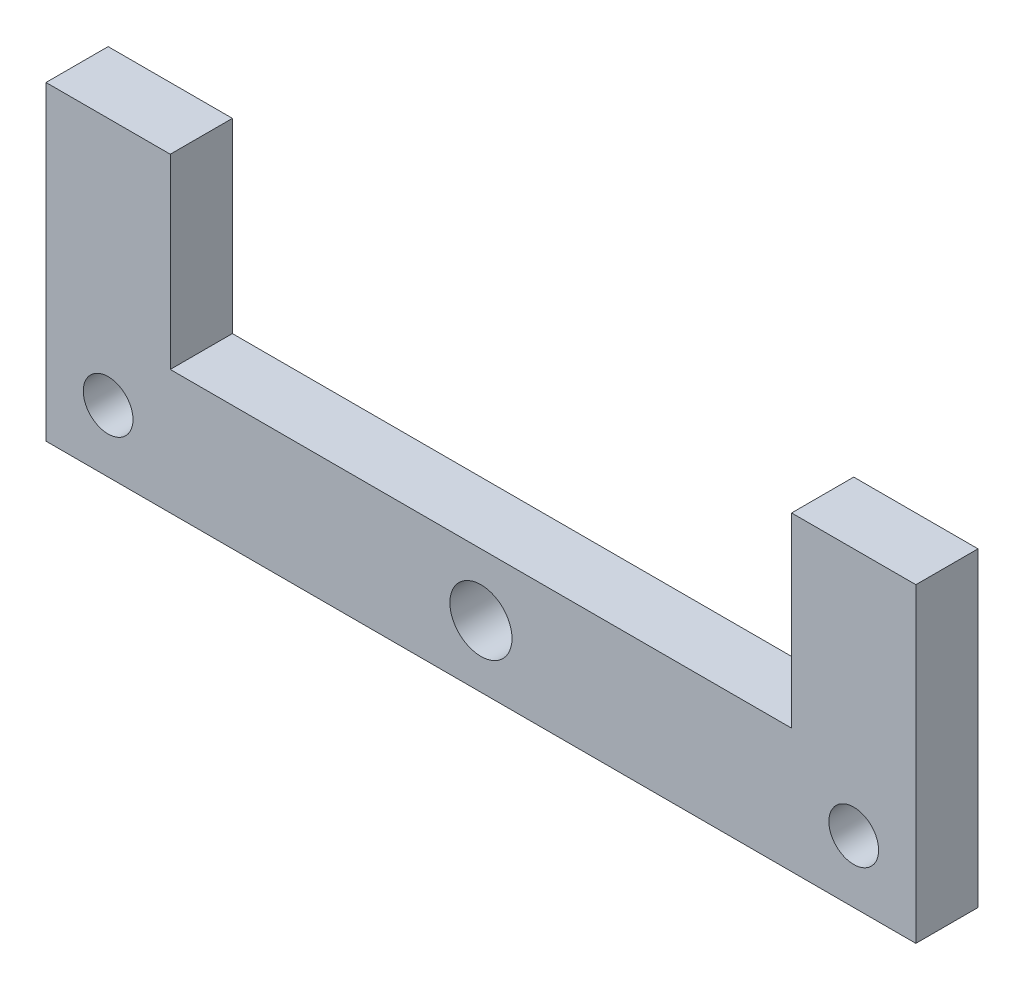
from build123d import *

# Parameters (mm, degrees)
ESQUISSE1_R        = 5
ESQUISSE1_R_2      = 4
BOSS_EXTRU_1_DEPTH = 10


with BuildPart() as part:
    # Esquisse1 → Boss.-Extru.1 (new body)
    with BuildSketch(Plane.XY):
        Polygon((-50, 10), (50, 10), (50, 40), (70, 40), (70, 10), (70, -10), (-70, -10), (-70, 10), (-70, 40), (-50, 40), align=None)
        Circle(ESQUISSE1_R, mode=Mode.SUBTRACT)
        with Locations((-60, 0)):
            Circle(ESQUISSE1_R_2, mode=Mode.SUBTRACT)
        with Locations((60, 0)):
            Circle(ESQUISSE1_R_2, mode=Mode.SUBTRACT)
    extrude(amount=BOSS_EXTRU_1_DEPTH)


solid = part.part
